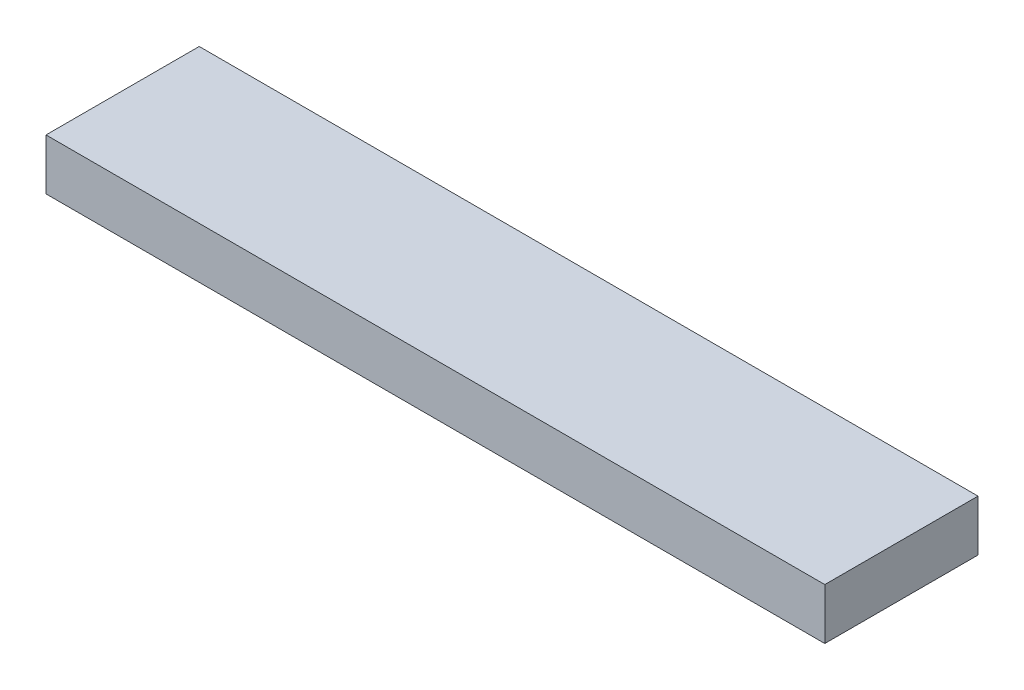
from build123d import *

# Parameters (mm, degrees)
SKETCH1_W           = 193.675
SKETCH1_H           = 38.1
BOSS_EXTRUDE1_DEPTH = 6.35


with BuildPart() as part:
    # Sketch1 → Boss-Extrude1 (new body, symmetric)
    with BuildSketch(Plane(origin=(0, 0, 0), x_dir=(1, 0, 0), z_dir=(0, 1, 0))):
        Rectangle(SKETCH1_W, SKETCH1_H)
    extrude(amount=BOSS_EXTRUDE1_DEPTH, both=True)


solid = part.part
